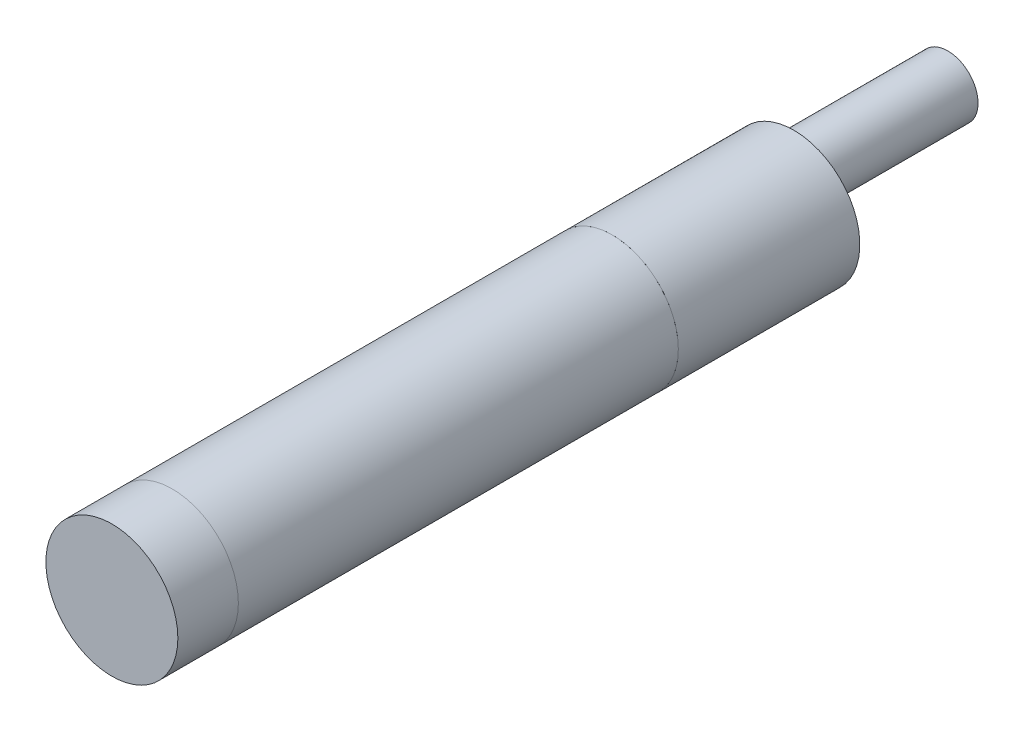
from build123d import *

# Parameters (mm, degrees)
SKETCH1_R           = 6
BOSS_EXTRUDE1_DEPTH = 40
SKETCH2_R           = 6
BOSS_EXTRUDE2_DEPTH = 5.5
SKETCH3_R           = 6
BOSS_EXTRUDE3_DEPTH = 16.5
SKETCH4_R           = 2.75
BOSS_EXTRUDE4_DEPTH = 14


with BuildPart() as part:
    # Sketch1 → Boss-Extrude1 (new body)
    with BuildSketch(Plane.XY):
        Circle(SKETCH1_R)
    extrude(amount=BOSS_EXTRUDE1_DEPTH)


with BuildPart() as body_2:
    # Sketch2 → Boss-Extrude2 (new body)
    with BuildSketch(Plane.XY.offset(40)):
        Circle(SKETCH2_R)
    extrude(amount=BOSS_EXTRUDE2_DEPTH)


with BuildPart() as body_3:
    # Sketch3 → Boss-Extrude3 (new body)
    with BuildSketch(Plane(origin=(0, 0, 0), x_dir=(-1, 0, 0), z_dir=(0, 0, -1))):
        Circle(SKETCH3_R)
    extrude(amount=BOSS_EXTRUDE3_DEPTH)

    # Sketch4 → Boss-Extrude4 (add)
    with BuildSketch(Plane(origin=(0, 0, -16.5), x_dir=(-1, 0, 0), z_dir=(0, 0, -1))):
        with Locations((0, 2.493327733)):
            Circle(SKETCH4_R)
    extrude(amount=BOSS_EXTRUDE4_DEPTH)


solid = Compound([part.part, body_2.part, body_3.part])
